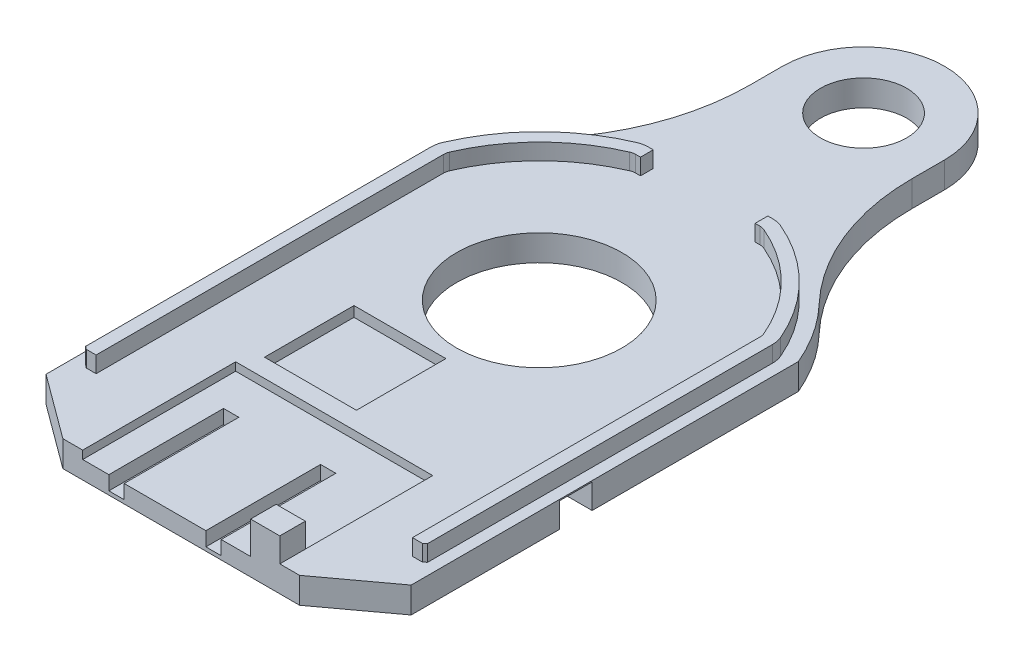
from build123d import *

# Parameters (mm, degrees)
SKETCH1_R               = 6.477
BOSS_EXTRUDE1_DEPTH     = 2.032
CUT_EXTRUDE1_DEPTH      = 0.64008
SKETCH3_W               = 1.19888
SKETCH3_H               = 8.98144
CUT_EXTRUDE2_DEPTH      = 1.09982
SKETCH4_W               = 7.19836
SKETCH4_H               = 7.00786
CUT_EXTRUDE3_DEPTH      = 0.8001
BOSS_EXTRUDE2_DEPTH     = 1.27
SKETCH6_W               = 2.286
SKETCH6_H               = 1.99898
BOSS_EXTRUDE3_DEPTH     = 2.54
SKETCH7_R               = 3.3734375
BOSS_EXTRUDE4_DEPTH     = 2.032
SKETCH8_W               = 2.54
SKETCH8_H               = 0.79375
CUT_EXTRUDE4_DEPTH      = 1
CUT_EXTRUDE4_DEPTH_BACK = 29.6004
CHAMFER1_SIZE           = 1.143
CHAMFER2_SIZE           = 1.143


with BuildPart() as part:
    # Sketch1 → Boss-Extrude1 (new body)
    with BuildSketch(Plane(origin=(0, 0, 0), x_dir=(1, 0, 0), z_dir=(0, 1, 0))):
        with BuildLine():
            Line((-14.3002, 5.9944), (-14.3002, -24.3332))
            Line((-14.3002, -24.3332), (-9.271, -28.0416))
            Line((-9.271, -28.0416), (9.271, -28.0416))
            Line((9.271, -28.0416), (14.3002, -24.3332))
            Line((14.3002, -24.3332), (14.3002, 5.9944))
            ThreePointArc((14.3002, 5.9944), (0, 15.505758653), (-14.3002, 5.9944))
        make_face()
        Circle(SKETCH1_R, mode=Mode.SUBTRACT)
    extrude(amount=BOSS_EXTRUDE1_DEPTH)

    # Sketch2 → Cut-Extrude1 (cut)
    with BuildSketch(Plane(origin=(0, 2.032, 0), x_dir=(1, 0, 0), z_dir=(0, 1, 0))):
        Polygon((0, -28.0416), (-7.71906, -28.0416), (-7.71906, -16.06042), (7.71906, -16.06042), (7.71906, -28.0416), align=None)
    extrude(amount=-CUT_EXTRUDE1_DEPTH, mode=Mode.SUBTRACT)

    # Sketch3 → Cut-Extrude2 (cut)
    with BuildSketch(Plane(origin=(0, 1.39192, 0), x_dir=(1, 0, 0), z_dir=(0, 1, 0))):
        with Locations((-5.06984, -23.55088)):
            Rectangle(SKETCH3_W, SKETCH3_H)
        with Locations((2.52984, -23.55088)):
            Rectangle(SKETCH3_W, SKETCH3_H)
    extrude(amount=-CUT_EXTRUDE2_DEPTH, mode=Mode.SUBTRACT)

    # Sketch4 → Cut-Extrude3 (cut)
    with BuildSketch(Plane(origin=(0, 2.032, 0), x_dir=(1, 0, 0), z_dir=(0, 1, 0))):
        with Locations((-3.299968, -11.116564)):
            Rectangle(SKETCH4_W, SKETCH4_H)
    extrude(amount=-CUT_EXTRUDE3_DEPTH, mode=Mode.SUBTRACT)

    # Sketch5 → Boss-Extrude2 (add)
    with BuildSketch(Plane(origin=(0, 2.032, 0), x_dir=(1, 0, 0), z_dir=(0, 1, 0))):
        with BuildLine():
            Line((12.40282, -22.33422), (13.171678, -22.33422))
            Line((13.171678, -22.33422), (13.40104, -22.152864))
            Line((13.40104, -22.152864), (13.40104, 4.882896))
            ThreePointArc((13.40104, 4.882896), (13.360125716, 5.283490726), (13.23975, 5.667756))
            ThreePointArc((13.23975, 5.667756), (10.160746855, 10.20631074), (5.608066, 13.264388))
            ThreePointArc((5.608066, 13.264388), (5.250053957, 13.366581837), (4.87934, 13.40104))
            Line((4.87934, 13.40104), (4.50342, 13.40104))
            Line((4.50342, 13.40104), (4.50342, 12.40282))
            Line((4.50342, 12.40282), (4.87934, 12.40282))
            ThreePointArc((4.87934, 12.40282), (5.080028543, 12.382451063), (5.272532, 12.322175))
            ThreePointArc((5.272532, 12.322175), (9.477779109, 9.479294357), (12.322175, 5.275072))
            ThreePointArc((12.322175, 5.275072), (12.382451063, 5.082568543), (12.40282, 4.88188))
            Line((12.40282, 4.88188), (12.40282, -22.33422))
        make_face()
        with BuildLine():
            Line((-4.850750436, 13.40104), (-4.474830436, 13.40104))
            Line((-4.474830436, 13.40104), (-4.474830436, 12.40282))
            Line((-4.474830436, 12.40282), (-4.850750436, 12.40282))
            ThreePointArc((-4.850750436, 12.40282), (-5.051438979, 12.382451063), (-5.243942436, 12.322175))
            ThreePointArc((-5.243942436, 12.322175), (-9.449189546, 9.479294357), (-12.293585436, 5.275072))
            ThreePointArc((-12.293585436, 5.275072), (-12.353861499, 5.082568543), (-12.374230436, 4.88188))
            Line((-12.374230436, 4.88188), (-12.374230436, -22.33422))
            Line((-12.374230436, -22.33422), (-13.143088436, -22.33422))
            Line((-13.143088436, -22.33422), (-13.372450436, -22.152864))
            Line((-13.372450436, -22.152864), (-13.372450436, 4.882896))
            ThreePointArc((-13.372450436, 4.882896), (-13.331536152, 5.283490726), (-13.211160436, 5.667756))
            ThreePointArc((-13.211160436, 5.667756), (-10.132157291, 10.20631074), (-5.579476436, 13.264388))
            ThreePointArc((-5.579476436, 13.264388), (-5.221464393, 13.366581837), (-4.850750436, 13.40104))
        make_face()
    extrude(amount=BOSS_EXTRUDE2_DEPTH)

    # Sketch6 → Boss-Extrude3 (add)
    with BuildSketch(Plane(origin=(0, 1.39192, 0), x_dir=(1, 0, 0), z_dir=(0, 1, 0))):
        with Locations((6.57606, -27.04211)):
            Rectangle(SKETCH6_W, SKETCH6_H)
    extrude(amount=BOSS_EXTRUDE3_DEPTH)

    # Sketch7 → Boss-Extrude4 (add)
    with BuildSketch(Plane.XZ):
        with BuildLine():
            Line((-6.35, -25.4), (-6.35, -22.86))
            ThreePointArc((-6.35, -22.86), (-7.612456929, -16.312404928), (-11.218821547, -10.703578583))
            ThreePointArc((-11.218821547, -10.703578583), (0, -15.505758653), (11.218821547, -10.703578583))
            ThreePointArc((11.218821547, -10.703578583), (7.612456929, -16.312404928), (6.35, -22.86))
            Line((6.35, -22.86), (6.35, -25.4))
            ThreePointArc((6.35, -25.4), (0, -31.75), (-6.35, -25.4))
        make_face()
        with Locations((0, -25.4)):
            Circle(SKETCH7_R, mode=Mode.SUBTRACT)
    extrude(amount=-BOSS_EXTRUDE4_DEPTH)

    # Sketch8 → Cut-Extrude4 (cut, two sides)
    with BuildSketch(Plane(origin=(14.3002, 0, 0), x_dir=(0, 0, -1), z_dir=(1, 0, 0))) as cut_extrude4_sk:
        with Locations((-11.43, 0.396875)):
            Rectangle(SKETCH8_W, SKETCH8_H)
    extrude(amount=CUT_EXTRUDE4_DEPTH, mode=Mode.SUBTRACT)
    extrude(cut_extrude4_sk.sketch, amount=-CUT_EXTRUDE4_DEPTH_BACK, mode=Mode.SUBTRACT)

    # Chamfer1
    chamfer1_edges = [part.edges().sort_by_distance(p)[0] for p in [
        (14.3002, 0.79375, 11.43),
    ]]
    chamfer(chamfer1_edges, length=CHAMFER1_SIZE)

    # Chamfer2
    chamfer2_edges = [part.edges().sort_by_distance(p)[0] for p in [
        (-14.3002, 0.79375, 11.43),
    ]]
    chamfer(chamfer2_edges, length=CHAMFER2_SIZE)


solid = part.part
